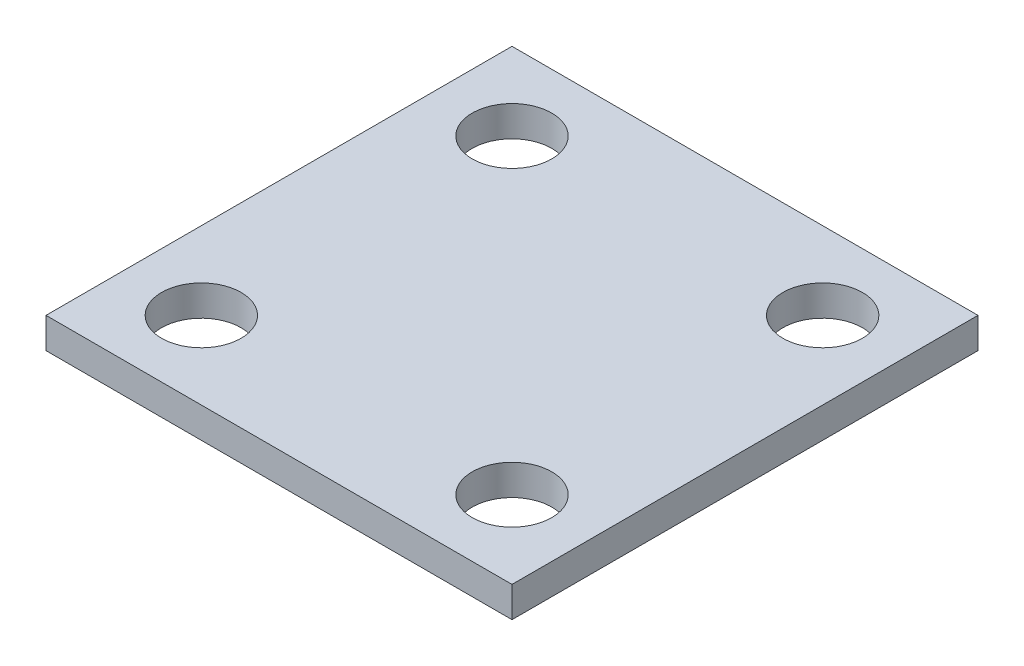
from build123d import *

# Parameters (mm, degrees)
SKETCH1_W           = 38.1
SKETCH1_H           = 38.1
SKETCH1_R           = 3.25
BOSS_EXTRUDE1_DEPTH = 2.5


with BuildPart() as part:
    # Sketch1 → Boss-Extrude1 (new body)
    with BuildSketch(Plane(origin=(0, 0, 0), x_dir=(1, 0, 0), z_dir=(0, 1, 0))):
        Rectangle(SKETCH1_W, SKETCH1_H)
        with Locations((-12.7, 12.7)):
            Circle(SKETCH1_R, mode=Mode.SUBTRACT)
        with Locations((12.7, 12.7)):
            Circle(SKETCH1_R, mode=Mode.SUBTRACT)
        with Locations((-12.7, -12.7)):
            Circle(SKETCH1_R, mode=Mode.SUBTRACT)
        with Locations((12.7, -12.7)):
            Circle(SKETCH1_R, mode=Mode.SUBTRACT)
    extrude(amount=BOSS_EXTRUDE1_DEPTH)


solid = part.part
